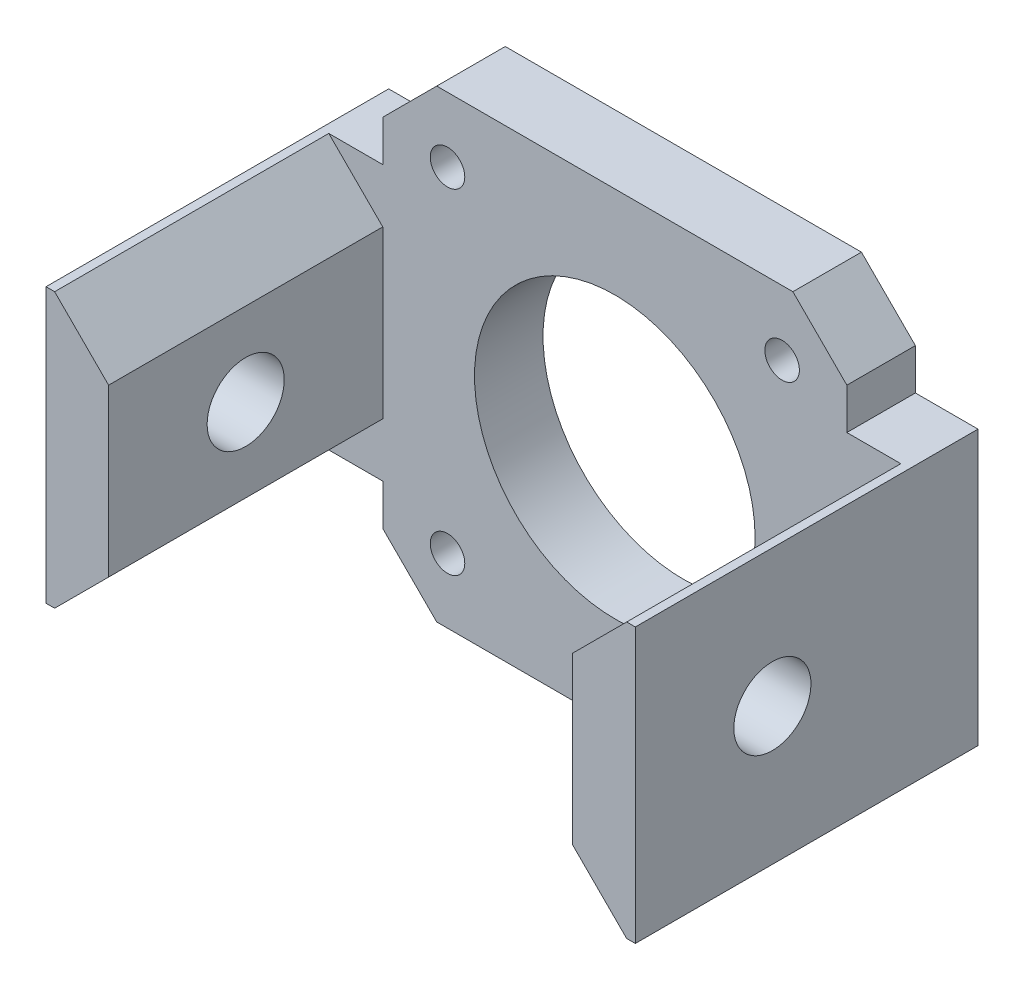
from build123d import *

# Parameters (mm, degrees)
SKETCH1_R               = 13
SKETCH1_R_2             = 1.6
BOSS_EXTRUDE1_DEPTH     = 6.35
SKETCH2_W               = 5.8
SKETCH2_H               = 43
BOSS_EXTRUDE2_DEPTH     = 25.4
CUT_EXTRUDE1_DEPTH      = 26.4
CUT_EXTRUDE1_DEPTH_BACK = 7.35
SKETCH5_R               = 3.571875
CUT_EXTRUDE2_DEPTH      = 49.8
CUT_EXTRUDE2_DEPTH_BACK = 6.8
CHAMFER1_SIZE           = 5


with BuildPart() as part:
    # Sketch1 → Boss-Extrude1 (new body)
    with BuildSketch(Plane.XY):
        Polygon((-21.5, 21.5), (21.5, 21.5), (27.3, 21.5), (27.3, -21.5), (21.5, -21.5), (-21.5, -21.5), (-27.3, -21.5), (-27.3, 21.5), align=None)
        Circle(SKETCH1_R, mode=Mode.SUBTRACT)
        with Locations((-15.5, 15.5)):
            Circle(SKETCH1_R_2, mode=Mode.SUBTRACT)
        with Locations((15.5, 15.5)):
            Circle(SKETCH1_R_2, mode=Mode.SUBTRACT)
        with Locations((15.5, -15.5)):
            Circle(SKETCH1_R_2, mode=Mode.SUBTRACT)
        with Locations((-15.5, -15.5)):
            Circle(SKETCH1_R_2, mode=Mode.SUBTRACT)
    extrude(amount=BOSS_EXTRUDE1_DEPTH)

    # Sketch2 → Boss-Extrude2 (add)
    with BuildSketch(Plane.XY.offset(6.35)):
        with Locations((-24.4, 0)):
            Rectangle(SKETCH2_W, SKETCH2_H)
        with Locations((24.4, 0)):
            Rectangle(SKETCH2_W, SKETCH2_H)
    extrude(amount=BOSS_EXTRUDE2_DEPTH)

    # Sketch4 → Cut-Extrude1 (cut, two sides)
    with BuildSketch(Plane.XY.offset(6.35)) as cut_extrude1_sk:
        Polygon((-27.3, 12.7), (-21.5, 12.7), (-21.5, 16.5), (-16.5, 21.5), (-21.5, 21.5), (-27.3, 21.5), align=None)
        Polygon((21.5, 21.5), (16.5, 21.5), (21.5, 16.5), (21.5, 12.7), (27.3, 12.7), (27.3, 21.5), align=None)
        Polygon((27.3, -21.5), (27.3, -12.7), (21.5, -12.7), (21.5, -16.5), (16.5, -21.5), (21.5, -21.5), align=None)
        Polygon((-27.3, -21.5), (-21.5, -21.5), (-16.5, -21.5), (-21.5, -16.5), (-21.5, -12.7), (-27.3, -12.7), align=None)
    extrude(amount=CUT_EXTRUDE1_DEPTH, mode=Mode.SUBTRACT)
    extrude(cut_extrude1_sk.sketch, amount=-CUT_EXTRUDE1_DEPTH_BACK, mode=Mode.SUBTRACT)

    # Sketch5 → Cut-Extrude2 (cut, two sides)
    with BuildSketch(Plane(origin=(-21.5, 0, 0), x_dir=(0, 0, -1), z_dir=(1, 0, 0))) as cut_extrude2_sk:
        with Locations((-19.05, 0)):
            Circle(SKETCH5_R)
    extrude(amount=CUT_EXTRUDE2_DEPTH, mode=Mode.SUBTRACT)
    extrude(cut_extrude2_sk.sketch, amount=-CUT_EXTRUDE2_DEPTH_BACK, mode=Mode.SUBTRACT)

    # Chamfer1
    chamfer1_edges = [part.edges().sort_by_distance(p)[0] for p in [
        (21.5, -12.7, 19.05),
        (-21.5, 12.7, 19.05),
        (-21.5, -12.7, 19.05),
        (21.5, 12.7, 19.05),
    ]]
    chamfer(chamfer1_edges, length=CHAMFER1_SIZE)


solid = part.part
